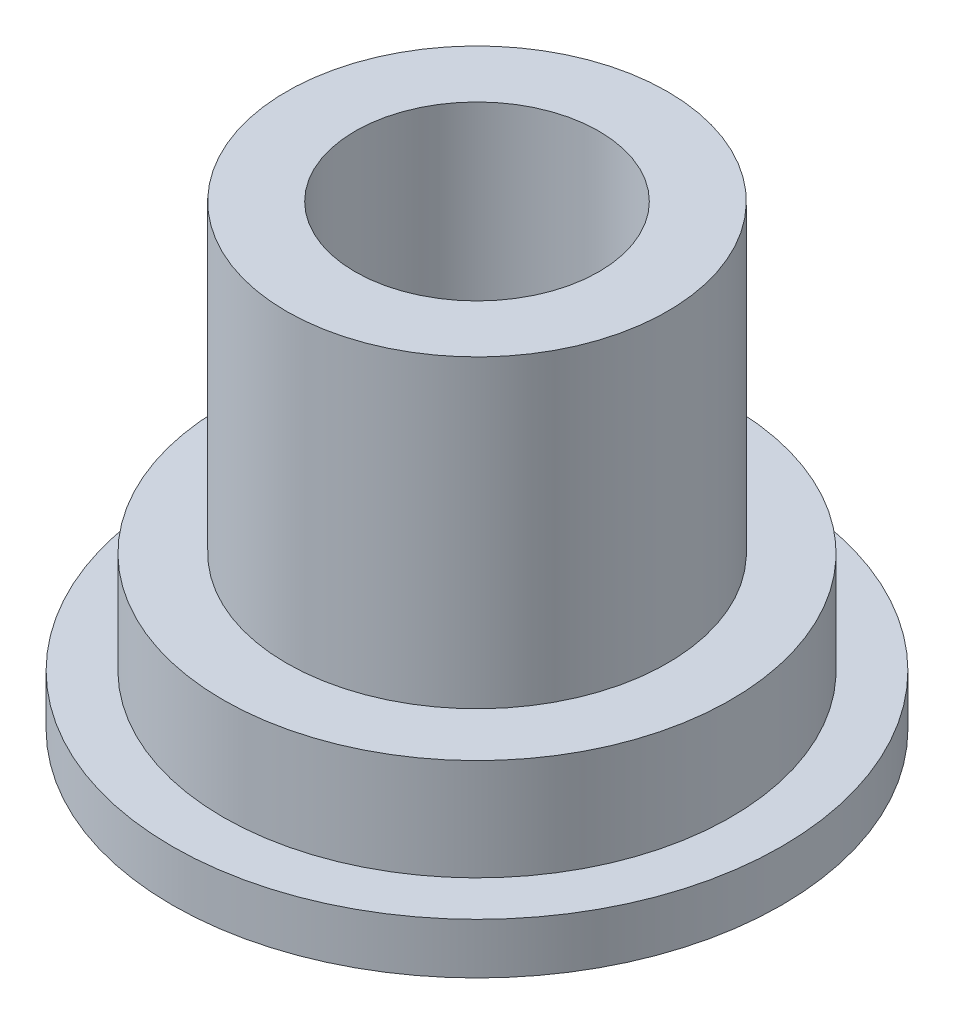
from build123d import *

# Parameters (mm, degrees)
SKETCH1_R               = 6.35
BOSS_EXTRUDE1_DEPTH     = 2.54
SKETCH2_R               = 4.7625
BOSS_EXTRUDE2_DEPTH     = 7.62
SKETCH3_R               = 3.048
CUT_EXTRUDE1_DEPTH      = 7.62
SKETCH6_R               = 7.62
BOSS_EXTRUDE3_DEPTH     = 1.27
SKETCH4_R               = 0.762
CUT_EXTRUDE2_DEPTH      = 8.62
CUT_EXTRUDE2_DEPTH_BACK = 4.81
SKETCH5_R               = 0.762
CUT_EXTRUDE3_DEPTH      = 4.81


with BuildPart() as part:
    # Sketch1 → Boss-Extrude1 (new body)
    with BuildSketch(Plane(origin=(0, 0, 0), x_dir=(1, 0, 0), z_dir=(0, 1, 0))):
        Circle(SKETCH1_R)
    extrude(amount=BOSS_EXTRUDE1_DEPTH)

    # Sketch2 → Boss-Extrude2 (add)
    with BuildSketch(Plane(origin=(0, 2.54, 0), x_dir=(1, 0, 0), z_dir=(0, 1, 0))):
        Circle(SKETCH2_R)
    extrude(amount=BOSS_EXTRUDE2_DEPTH)

    # Sketch3 → Cut-Extrude1 (cut)
    with BuildSketch(Plane(origin=(0, 10.16, 0), x_dir=(1, 0, 0), z_dir=(0, 1, 0))):
        Circle(SKETCH3_R)
    extrude(amount=-CUT_EXTRUDE1_DEPTH, mode=Mode.SUBTRACT)

    # Sketch6 → Boss-Extrude3 (add)
    with BuildSketch(Plane.XZ):
        Circle(SKETCH6_R)
    extrude(amount=BOSS_EXTRUDE3_DEPTH)

    # Sketch4 → Cut-Extrude2 (cut, two sides)
    with BuildSketch(Plane(origin=(0, 2.54, 0), x_dir=(1, 0, 0), z_dir=(0, 1, 0))) as cut_extrude2_sk:
        with Locations((0, -1.27)):
            Circle(SKETCH4_R)
    extrude(amount=CUT_EXTRUDE2_DEPTH, mode=Mode.SUBTRACT)
    extrude(cut_extrude2_sk.sketch, amount=-CUT_EXTRUDE2_DEPTH_BACK, mode=Mode.SUBTRACT)

    # Sketch5 → Cut-Extrude3 (cut, through all)
    with BuildSketch(Plane(origin=(0, 2.54, 0), x_dir=(1, 0, 0), z_dir=(0, 1, 0))):
        with Locations((0, 1.27)):
            Circle(SKETCH5_R)
    extrude(amount=-CUT_EXTRUDE3_DEPTH, mode=Mode.SUBTRACT)


solid = part.part
